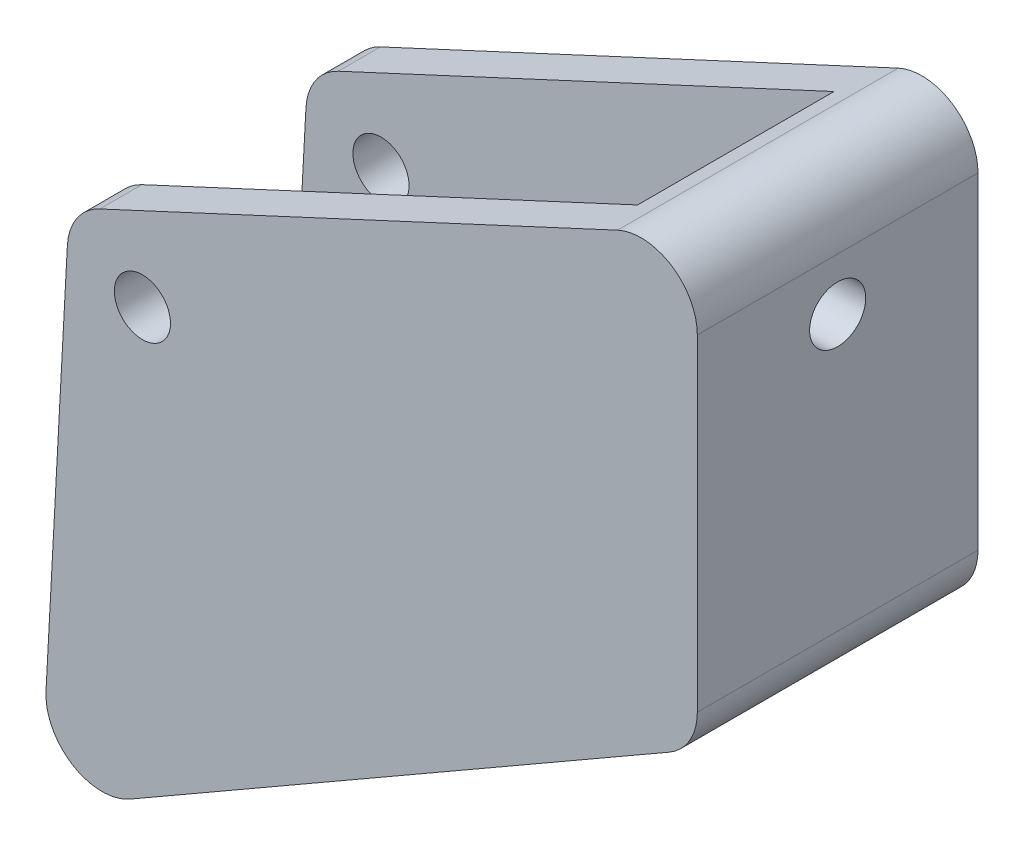
from build123d import *

# Parameters (mm, degrees)
BOSS_EXTRU_2_DEPTH      = 25
ENL_V_MAT_EXTRU_1_DEPTH = 17.5
ESQUISSE3_R             = 5
ENL_V_MAT_EXTRU_2_DEPTH = 141.346637083
CONG_1_R                = 10
CONG_2_R                = 10
CONG_3_R                = 10
ESQUISSE5_R             = 5
ENL_V_MAT_EXTRU_3_DEPTH = 131.788342052


with BuildPart() as part:
    # Esquisse1 → Boss.-Extru.2 (new, symmetric)
    with BuildSketch(Plane.XY):
        Polygon((98.849698137, 60.802751576), (-13.043991627, 8.826246926), (-18.162962303, -86.173753074), (98.849698137, -18.845918586), align=None)
    extrude(amount=BOSS_EXTRU_2_DEPTH, both=True)

    # Esquisse2 → Enlèv. mat.-Extru.1 (cut, symmetric)
    with BuildSketch(Plane.XY):
        Polygon((-16.815864757, -61.173753074), (82.946312501, -14.832540436), (80.711120454, 52.377076551), (-13.043991627, 8.826246926), align=None)
    extrude(amount=ENL_V_MAT_EXTRU_1_DEPTH, both=True, mode=Mode.SUBTRACT)

    # Esquisse3 → Enlèv. mat.-Extru.2 (cut, through all)
    with BuildSketch(Plane.XY.offset(25)):
        Circle(ESQUISSE3_R)
    extrude(amount=-ENL_V_MAT_EXTRU_2_DEPTH, mode=Mode.SUBTRACT)

    # Congé1
    cong_1_edges = [part.edges().sort_by_distance(p)[0] for p in [
        (-13.043991627, 8.826246926, -21.25),
        (-13.043991627, 8.826246926, 21.25),
    ]]
    fillet(cong_1_edges, radius=CONG_1_R)

    # Congé2
    cong_2_edges = [part.edges().sort_by_distance(p)[0] for p in [
        (-18.162962303, -86.173753074, 0),
    ]]
    fillet(cong_2_edges, radius=CONG_2_R)

    # Congé3
    cong_3_edges = [part.edges().sort_by_distance(p)[0] for p in [
        (98.849698137, 60.802751576, 0),
        (98.849698137, -18.845918586, 0),
    ]]
    fillet(cong_3_edges, radius=CONG_3_R)

    # Esquisse5 → Enlèv. mat.-Extru.3 (cut, through all)
    with BuildSketch(Plane(origin=(82.361931549, 2.739112982, 0), x_dir=(0, 0, 1), z_dir=(-0.9994474433929438, -0.03323865062406649, 0))):
        with Locations((0, 32.532014282)):
            Circle(ESQUISSE5_R)
    extrude(amount=-ENL_V_MAT_EXTRU_3_DEPTH, mode=Mode.SUBTRACT)


solid = part.part
